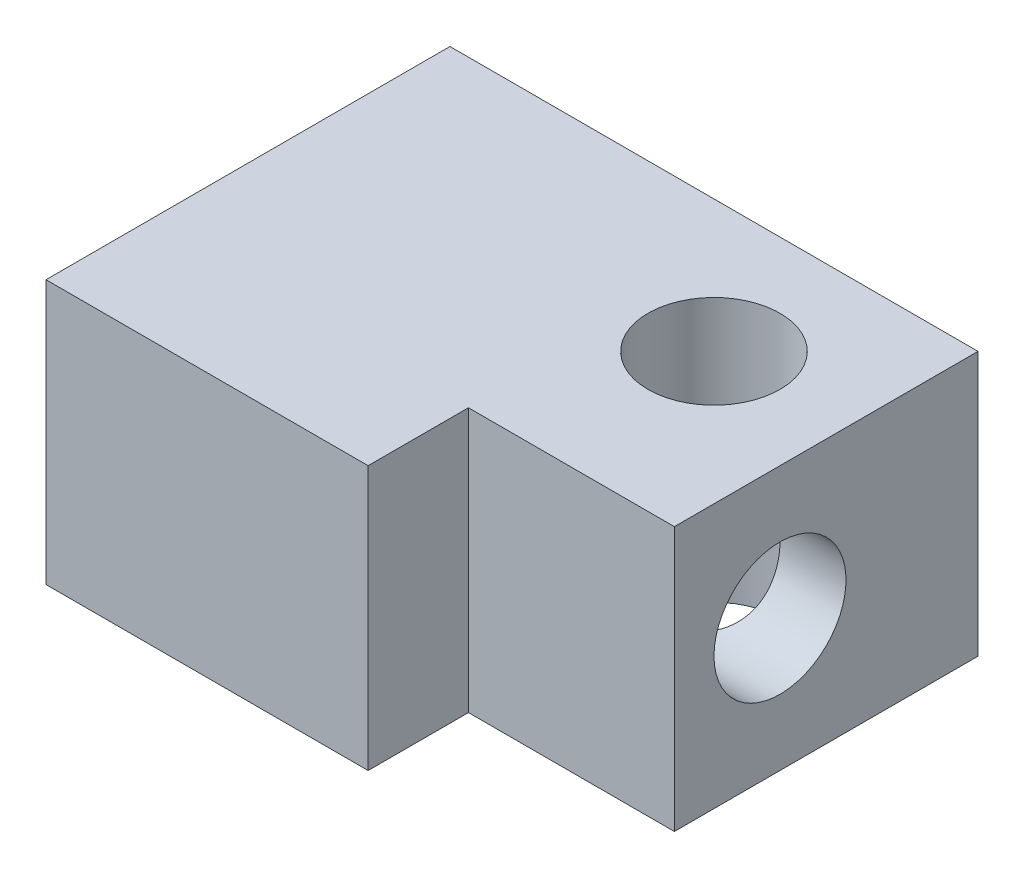
from build123d import *

# Parameters (mm, degrees)
SKETCH4_R           = 1.25
BOSS_EXTRUDE1_DEPTH = 5
CUT_EXTRUDE1_DEPTH  = 10


with BuildPart() as part:
    # Sketch4 → Boss-Extrude1 (new body)
    with BuildSketch(Plane(origin=(0, 0, 0), x_dir=(1, 0, 0), z_dir=(0, 1, 0))):
        Polygon((3.6, -10.15), (3.6, -8.25), (7.5, -8.25), (7.5, -2.5), (-2.5, -2.5), (-2.5, -10.15), align=None)
        with Locations((5, -5)):
            Circle(SKETCH4_R, mode=Mode.SUBTRACT)
    extrude(amount=BOSS_EXTRUDE1_DEPTH)

    # Sketch5 → Cut-Extrude1 (cut)
    with BuildSketch(Plane.ZY.offset(2.5)):
        with BuildLine():
            ThreePointArc((6.25, 3.75), (5, 2.5), (6.25, 1.25))
            Line((6.25, 1.25), (6.25, 3.75))
        make_face()
        with BuildLine():
            Line((6.25, 3.75), (6.25, 1.25))
            ThreePointArc((6.25, 1.25), (7.133883476, 1.616116524), (7.5, 2.5))
            ThreePointArc((7.5, 2.5), (7.133883476, 3.383883476), (6.25, 3.75))
        make_face()
    extrude(amount=-CUT_EXTRUDE1_DEPTH, mode=Mode.SUBTRACT)


solid = part.part
